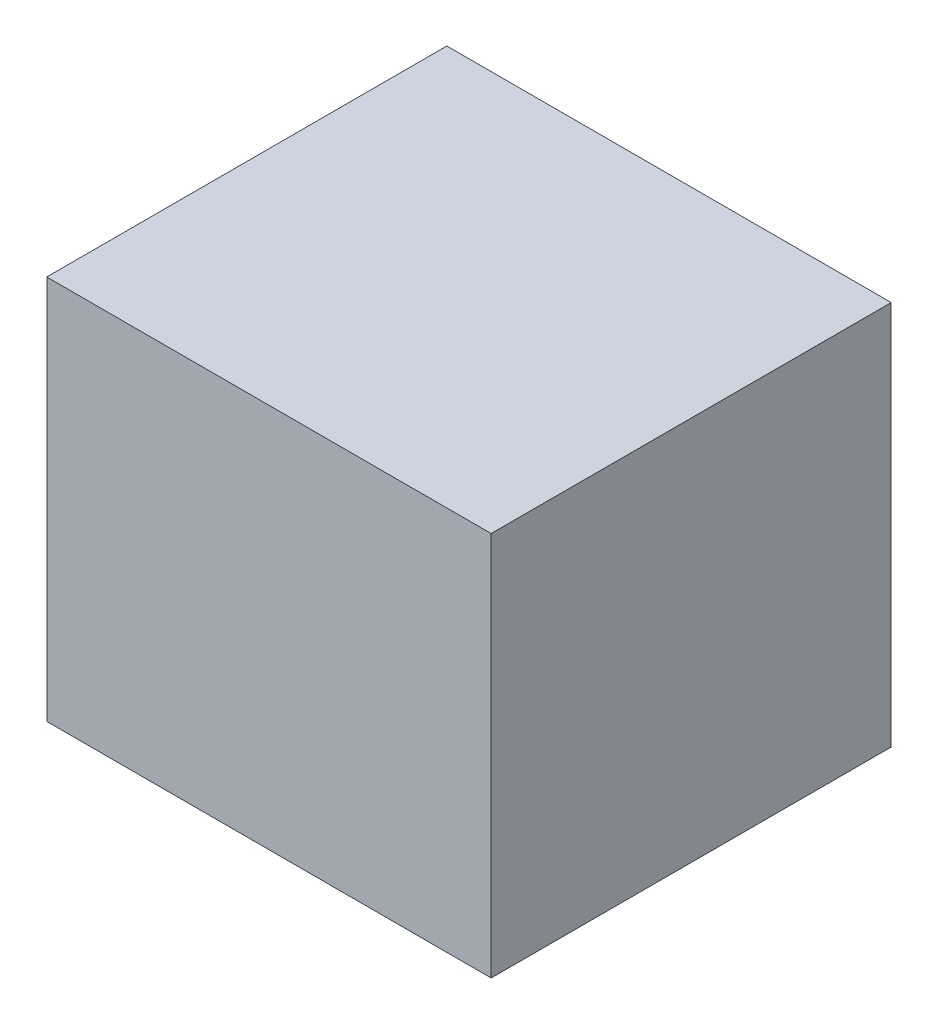
from build123d import *

# Parameters (mm, degrees)
SKETCH1_W           = 7.62
SKETCH1_H           = 6.86
BOSS_EXTRUDE1_DEPTH = 6.6


with BuildPart() as part:
    # Sketch1 → Boss-Extrude1 (new body)
    with BuildSketch(Plane(origin=(0, 0, 0), x_dir=(1, 0, 0), z_dir=(0, 1, 0))):
        Rectangle(SKETCH1_W, SKETCH1_H)
    extrude(amount=BOSS_EXTRUDE1_DEPTH)


solid = part.part
